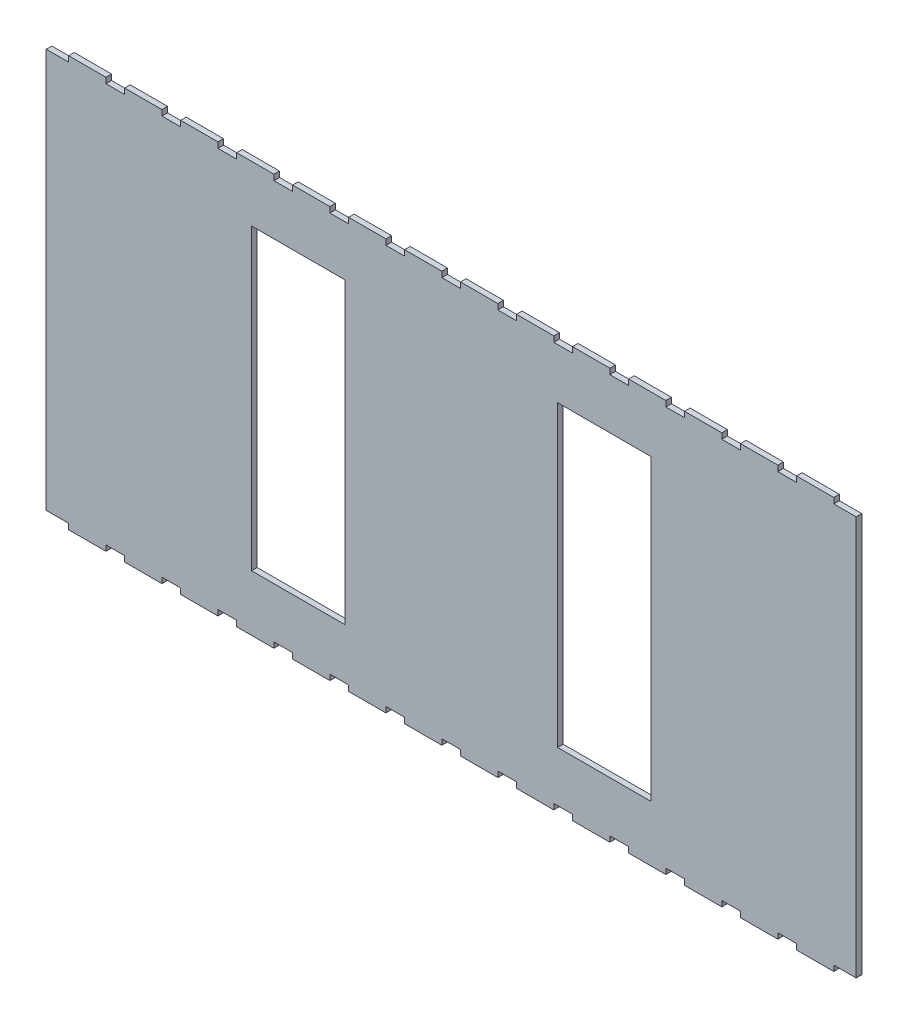
from build123d import *

# Parameters (mm, degrees)
ESQUISSE1_W             = 434
ESQUISSE1_H             = 220
BOSS_EXTRU_1_DEPTH      = 3
ESQUISSE2_W             = 10
ESQUISSE2_H             = 3
ESQUISSE2_W_2           = 2
ENL_V_MAT_EXTRU_1_DEPTH = 3
ESQUISSE3_W             = 50
ESQUISSE3_H             = 160
ENL_V_MAT_EXTRU_2_DEPTH = 3


with BuildPart() as part:
    # Esquisse1 → Boss.-Extru.1 (new body)
    with BuildSketch(Plane.XY):
        Rectangle(ESQUISSE1_W, ESQUISSE1_H)
    extrude(amount=BOSS_EXTRU_1_DEPTH)

    # Esquisse2 → Enlèv. mat.-Extru.1 (cut)
    with BuildSketch(Plane.XY.offset(3)):
        with Locations((-210, 108.5)):
            Rectangle(ESQUISSE2_W, ESQUISSE2_H)
        with Locations((-180, 108.5)):
            Rectangle(ESQUISSE2_W, ESQUISSE2_H)
        with Locations((-150, 108.5)):
            Rectangle(ESQUISSE2_W, ESQUISSE2_H)
        with Locations((-120, 108.5)):
            Rectangle(ESQUISSE2_W, ESQUISSE2_H)
        with Locations((-90, 108.5)):
            Rectangle(ESQUISSE2_W, ESQUISSE2_H)
        with Locations((-30, 108.5)):
            Rectangle(ESQUISSE2_W, ESQUISSE2_H)
        with Locations((30, 108.5)):
            Rectangle(ESQUISSE2_W, ESQUISSE2_H)
        with Locations((60, 108.5)):
            Rectangle(ESQUISSE2_W, ESQUISSE2_H)
        with Locations((90, 108.5)):
            Rectangle(ESQUISSE2_W, ESQUISSE2_H)
        with Locations((120, 108.5)):
            Rectangle(ESQUISSE2_W, ESQUISSE2_H)
        with Locations((150, 108.5)):
            Rectangle(ESQUISSE2_W, ESQUISSE2_H)
        with Locations((180, 108.5)):
            Rectangle(ESQUISSE2_W, ESQUISSE2_H)
        with Locations((210, 108.5)):
            Rectangle(ESQUISSE2_W, ESQUISSE2_H)
        with Locations((210, -108.5)):
            Rectangle(ESQUISSE2_W, ESQUISSE2_H)
        with Locations((180, -108.5)):
            Rectangle(ESQUISSE2_W, ESQUISSE2_H)
        with Locations((150, -108.5)):
            Rectangle(ESQUISSE2_W, ESQUISSE2_H)
        with Locations((90, -108.5)):
            Rectangle(ESQUISSE2_W, ESQUISSE2_H)
        with Locations((60, -108.5)):
            Rectangle(ESQUISSE2_W, ESQUISSE2_H)
        with Locations((-30, -108.5)):
            Rectangle(ESQUISSE2_W, ESQUISSE2_H)
        with Locations((-60, -108.5)):
            Rectangle(ESQUISSE2_W, ESQUISSE2_H)
        with Locations((-90, -108.5)):
            Rectangle(ESQUISSE2_W, ESQUISSE2_H)
        with Locations((-120, -108.5)):
            Rectangle(ESQUISSE2_W, ESQUISSE2_H)
        with Locations((-150, -108.5)):
            Rectangle(ESQUISSE2_W, ESQUISSE2_H)
        with Locations((-210, -108.5)):
            Rectangle(ESQUISSE2_W, ESQUISSE2_H)
        with Locations((-180, -108.5)):
            Rectangle(ESQUISSE2_W, ESQUISSE2_H)
        with Locations((-216, -108.5)):
            Rectangle(ESQUISSE2_W_2, ESQUISSE2_H)
        with Locations((-216, 108.5)):
            Rectangle(ESQUISSE2_W_2, ESQUISSE2_H)
        with Locations((-60, 108.5)):
            Rectangle(ESQUISSE2_W, ESQUISSE2_H)
        with Locations((0, 108.5)):
            Rectangle(ESQUISSE2_W, ESQUISSE2_H)
        with Locations((120, -108.5)):
            Rectangle(ESQUISSE2_W, ESQUISSE2_H)
        with Locations((30, -108.5)):
            Rectangle(ESQUISSE2_W, ESQUISSE2_H)
        with Locations((0, -108.5)):
            Rectangle(ESQUISSE2_W, ESQUISSE2_H)
        with Locations((216, 108.5)):
            Rectangle(ESQUISSE2_W_2, ESQUISSE2_H)
        with Locations((216, -108.5)):
            Rectangle(ESQUISSE2_W_2, ESQUISSE2_H)
    extrude(amount=-ENL_V_MAT_EXTRU_1_DEPTH, mode=Mode.SUBTRACT)

    # Esquisse3 → Enlèv. mat.-Extru.2 (cut)
    with BuildSketch(Plane.XY.offset(3)):
        with Locations((-82, 0)):
            Rectangle(ESQUISSE3_W, ESQUISSE3_H)
        with Locations((82, 0)):
            Rectangle(ESQUISSE3_W, ESQUISSE3_H)
    extrude(amount=-ENL_V_MAT_EXTRU_2_DEPTH, mode=Mode.SUBTRACT)


solid = part.part
